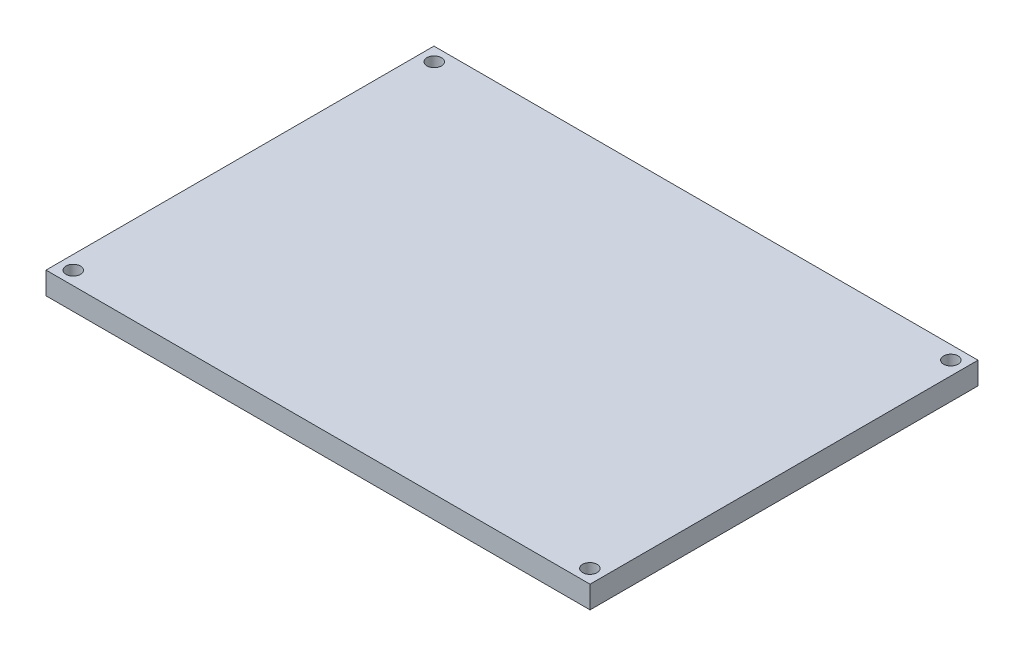
from build123d import *

# Parameters (mm, degrees)
SKETCH1_W           = 122
SKETCH1_H           = 87
SKETCH1_R           = 1.625
BOSS_EXTRUDE1_DEPTH = 5


with BuildPart() as part:
    # Sketch1 → Boss-Extrude1 (new body)
    with BuildSketch(Plane(origin=(0, 0, 0), x_dir=(1, 0, 0), z_dir=(0, 1, 0))):
        Rectangle(SKETCH1_W, SKETCH1_H)
        with Locations((57.925, 40.475)):
            Circle(SKETCH1_R, mode=Mode.SUBTRACT)
        with Locations((-57.925, 40.475)):
            Circle(SKETCH1_R, mode=Mode.SUBTRACT)
        with Locations((-57.925, -40.475)):
            Circle(SKETCH1_R, mode=Mode.SUBTRACT)
        with Locations((57.925, -40.475)):
            Circle(SKETCH1_R, mode=Mode.SUBTRACT)
    extrude(amount=BOSS_EXTRUDE1_DEPTH)


solid = part.part
